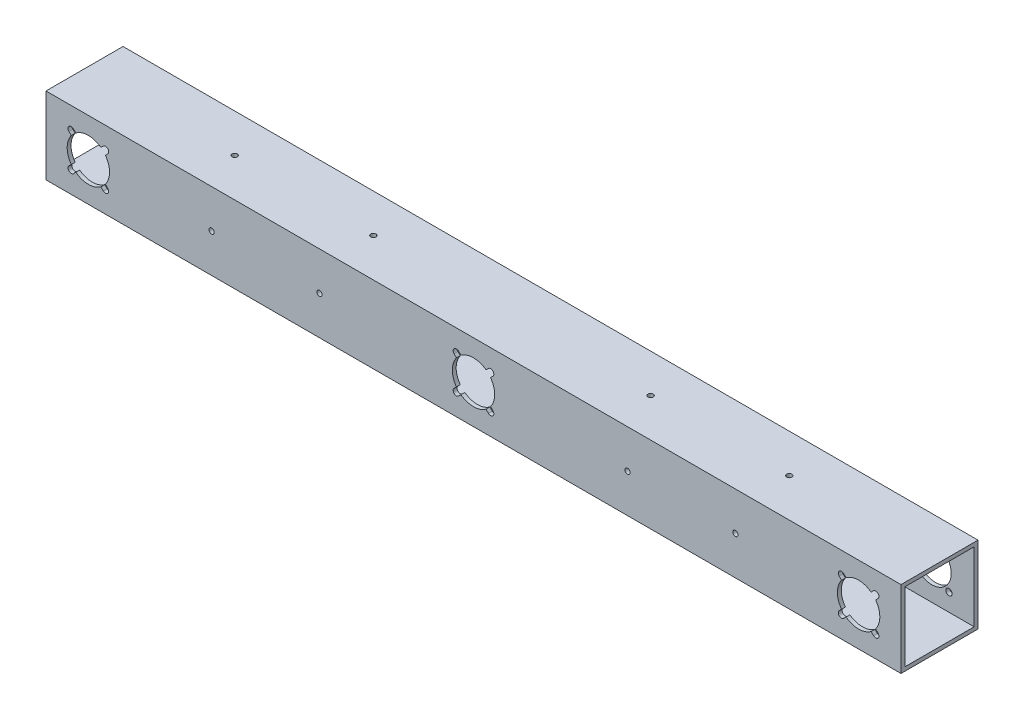
from build123d import *

# Parameters (mm, degrees)
SKETCH1_W           = 63.5
SKETCH1_H           = 63.5
BOSS_EXTRUDE1_DEPTH = 704.85
SKETCH2_W           = 57.15
SKETCH2_H           = 57.15
CUT_EXTRUDE1_DEPTH  = 705.85
CUT_EXTRUDE2_REACH  = 65.5
SKETCH3_R           = 17.4625
SKETCH8_R           = 2.15265
CUT_EXTRUDE6_DEPTH  = 64.5
SKETCH10_R          = 2.15265
CUT_EXTRUDE7_DEPTH  = 64.5
CUT_EXTRUDE9_REACH  = 65.5
SKETCH13_R          = 16
SKETCH14_R          = 2.625
SKETCH14_R_2        = 16
CUT_EXTRUDE10_DEPTH = 3.175
CUT_EXTRUDE11_START = -3.175
CUT_EXTRUDE11_DEPTH = 3.175
CUT_EXTRUDE13_REACH = 65.5
SKETCH17_W          = 19.05
SKETCH17_H          = 25.4


with BuildPart() as part:
    # Sketch1 → Boss-Extrude1 (new body)
    with BuildSketch(Plane(origin=(0, 0, 0), x_dir=(0, 0, -1), z_dir=(1, 0, 0))):
        Rectangle(SKETCH1_W, SKETCH1_H)
    extrude(amount=BOSS_EXTRUDE1_DEPTH)

    # Sketch2 → Cut-Extrude1 (cut, through all)
    with BuildSketch(Plane(origin=(704.85, 0, 0), x_dir=(0, 0, -1), z_dir=(1, 0, 0))):
        Rectangle(SKETCH2_W, SKETCH2_H)
    extrude(amount=-CUT_EXTRUDE1_DEPTH, mode=Mode.SUBTRACT)

    # Sketch3 → Cut-Extrude2 (cut, up to next)
    with BuildSketch(Plane.XY.offset(31.75), mode=Mode.PRIVATE) as cut_extrude2_sk1:
        with Locations((352.425, 0)):
            Circle(SKETCH3_R)
    cut_extrude2_tool1 = extrude(cut_extrude2_sk1.sketch, amount=-CUT_EXTRUDE2_REACH, mode=Mode.PRIVATE) & part.part
    add(cut_extrude2_tool1.solids().sort_by_distance((352.425, 0, 31.75))[0], mode=Mode.SUBTRACT)
    # Sketch3 → Cut-Extrude2 (cut, up to next)
    with BuildSketch(Plane.XY.offset(31.75), mode=Mode.PRIVATE) as cut_extrude2_sk2:
        with Locations((34.925, 0)):
            Circle(SKETCH3_R)
    cut_extrude2_tool2 = extrude(cut_extrude2_sk2.sketch, amount=-CUT_EXTRUDE2_REACH, mode=Mode.PRIVATE) & part.part
    add(cut_extrude2_tool2.solids().sort_by_distance((34.925, 0, 31.75))[0], mode=Mode.SUBTRACT)
    # Sketch3 → Cut-Extrude2 (cut, up to next)
    with BuildSketch(Plane.XY.offset(31.75), mode=Mode.PRIVATE) as cut_extrude2_sk3:
        with Locations((669.925, 0)):
            Circle(SKETCH3_R)
    cut_extrude2_tool3 = extrude(cut_extrude2_sk3.sketch, amount=-CUT_EXTRUDE2_REACH, mode=Mode.PRIVATE) & part.part
    add(cut_extrude2_tool3.solids().sort_by_distance((669.925, 0, 31.75))[0], mode=Mode.SUBTRACT)

    # Sketch8 → Cut-Extrude6 (cut, through all)
    with BuildSketch(Plane(origin=(0, 31.75, 0), x_dir=(1, 0, 0), z_dir=(0, 1, 0))):
        with Locations((466.725, 0)):
            Circle(SKETCH8_R)
        with Locations((123.825, 0)):
            Circle(SKETCH8_R)
        with Locations((581.025, 0)):
            Circle(SKETCH8_R)
        with Locations((238.125, 0)):
            Circle(SKETCH8_R)
    extrude(amount=-CUT_EXTRUDE6_DEPTH, mode=Mode.SUBTRACT)

    # Sketch10 → Cut-Extrude7 (cut, through all)
    with BuildSketch(Plane.XY.offset(31.75)):
        with Locations((225.425, 0)):
            Circle(SKETCH10_R)
        with Locations((568.325, 0)):
            Circle(SKETCH10_R)
        with Locations((136.525, 0)):
            Circle(SKETCH10_R)
        with Locations((479.425, 0)):
            Circle(SKETCH10_R)
    extrude(amount=-CUT_EXTRUDE7_DEPTH, mode=Mode.SUBTRACT)

    # Sketch13 → Cut-Extrude9 (cut, up to next)
    with BuildSketch(Plane(origin=(0, 0, -31.75), x_dir=(-1, 0, 0), z_dir=(0, 0, -1)), mode=Mode.PRIVATE) as cut_extrude9_sk1:
        with Locations((-352.425, 0)):
            Circle(SKETCH13_R)
    cut_extrude9_tool1 = extrude(cut_extrude9_sk1.sketch, amount=-CUT_EXTRUDE9_REACH, mode=Mode.PRIVATE) & part.part
    add(cut_extrude9_tool1.solids().sort_by_distance((352.425, 0, -31.75))[0], mode=Mode.SUBTRACT)
    # Sketch13 → Cut-Extrude9 (cut, up to next)
    with BuildSketch(Plane(origin=(0, 0, -31.75), x_dir=(-1, 0, 0), z_dir=(0, 0, -1)), mode=Mode.PRIVATE) as cut_extrude9_sk2:
        with Locations((-34.925, 0)):
            Circle(SKETCH13_R)
    cut_extrude9_tool2 = extrude(cut_extrude9_sk2.sketch, amount=-CUT_EXTRUDE9_REACH, mode=Mode.PRIVATE) & part.part
    add(cut_extrude9_tool2.solids().sort_by_distance((34.925, 0, -31.75))[0], mode=Mode.SUBTRACT)
    # Sketch13 → Cut-Extrude9 (cut, up to next)
    with BuildSketch(Plane(origin=(0, 0, -31.75), x_dir=(-1, 0, 0), z_dir=(0, 0, -1)), mode=Mode.PRIVATE) as cut_extrude9_sk3:
        with Locations((-669.925, 0)):
            Circle(SKETCH13_R)
    cut_extrude9_tool3 = extrude(cut_extrude9_sk3.sketch, amount=-CUT_EXTRUDE9_REACH, mode=Mode.PRIVATE) & part.part
    add(cut_extrude9_tool3.solids().sort_by_distance((669.925, 0, -31.75))[0], mode=Mode.SUBTRACT)

    # Sketch14 → Cut-Extrude10 (cut)
    with BuildSketch(Plane(origin=(0, 0, -31.75), x_dir=(-1, 0, 0), z_dir=(0, 0, -1))):
        with Locations((-655.782864376, 14.142135624)):
            Circle(SKETCH14_R)
        with Locations((-338.282864376, 14.142135624)):
            Circle(SKETCH14_R)
        with Locations((-20.782864376, 14.142135624)):
            Circle(SKETCH14_R)
        with Locations((-352.425, 0)):
            Circle(SKETCH14_R_2)
        with Locations((-34.925, 0)):
            Circle(SKETCH14_R_2)
        with Locations((-669.925, 0)):
            Circle(SKETCH14_R_2)
        with Locations((-338.282864376, -14.142135624)):
            Circle(SKETCH14_R)
        with Locations((-366.567135624, -14.142135624)):
            Circle(SKETCH14_R)
        with Locations((-366.567135624, 14.142135624)):
            Circle(SKETCH14_R)
        with Locations((-20.782864376, -14.142135624)):
            Circle(SKETCH14_R)
        with Locations((-49.067135624, -14.142135624)):
            Circle(SKETCH14_R)
        with Locations((-49.067135624, 14.142135624)):
            Circle(SKETCH14_R)
        with Locations((-655.782864376, -14.142135624)):
            Circle(SKETCH14_R)
        with Locations((-684.067135624, -14.142135624)):
            Circle(SKETCH14_R)
        with Locations((-684.067135624, 14.142135624)):
            Circle(SKETCH14_R)
    extrude(amount=-CUT_EXTRUDE10_DEPTH, mode=Mode.SUBTRACT)

    # Sketch15 → Cut-Extrude11 (cut)
    with BuildSketch(Plane.XY.offset(31.75).offset(CUT_EXTRUDE11_START)):
        with BuildLine():
            Line((364.710980323, -15.998290924), (362.776389114, -14.063699715))
            ThreePointArc((362.776389114, -14.063699715), (352.425, -17.4625), (342.073610886, -14.063699715))
            Line((342.073610886, -14.063699715), (340.139019677, -15.998290924))
            ThreePointArc((340.139019677, -15.998290924), (336.426709076, -15.998290924), (336.426709076, -12.285980323))
            Line((336.426709076, -12.285980323), (338.361300285, -10.351389114))
            ThreePointArc((338.361300285, -10.351389114), (334.9625, 0), (338.361300285, 10.351389114))
            Line((338.361300285, 10.351389114), (336.426709076, 12.285980323))
            ThreePointArc((336.426709076, 12.285980323), (336.426709076, 15.998290924), (340.139019677, 15.998290924))
            Line((340.139019677, 15.998290924), (342.073610886, 14.063699715))
            ThreePointArc((342.073610886, 14.063699715), (352.425, 17.4625), (362.776389114, 14.063699715))
            Line((362.776389114, 14.063699715), (364.710980323, 15.998290924))
            ThreePointArc((364.710980323, 15.998290924), (368.423290924, 15.998290924), (368.423290924, 12.285980323))
            Line((368.423290924, 12.285980323), (366.488699715, 10.351389114))
            ThreePointArc((366.488699715, 10.351389114), (369.8875, 0), (366.488699715, -10.351389114))
            Line((366.488699715, -10.351389114), (368.423290924, -12.285980323))
            ThreePointArc((368.423290924, -12.285980323), (368.423290924, -15.998290924), (364.710980323, -15.998290924))
        make_face()
        with BuildLine():
            Line((50.923290924, 12.285980323), (48.988699715, 10.351389114))
            ThreePointArc((48.988699715, 10.351389114), (52.3875, 0), (48.988699715, -10.351389114))
            Line((48.988699715, -10.351389114), (50.923290924, -12.285980323))
            ThreePointArc((50.923290924, -12.285980323), (50.923290924, -15.998290924), (47.210980323, -15.998290924))
            Line((47.210980323, -15.998290924), (45.276389114, -14.063699715))
            ThreePointArc((45.276389114, -14.063699715), (34.925, -17.4625), (24.573610886, -14.063699715))
            Line((24.573610886, -14.063699715), (22.639019677, -15.998290924))
            ThreePointArc((22.639019677, -15.998290924), (18.926709076, -15.998290924), (18.926709076, -12.285980323))
            Line((18.926709076, -12.285980323), (20.861300285, -10.351389114))
            ThreePointArc((20.861300285, -10.351389114), (17.4625, 0), (20.861300285, 10.351389114))
            Line((20.861300285, 10.351389114), (18.926709076, 12.285980323))
            ThreePointArc((18.926709076, 12.285980323), (18.926709076, 15.998290924), (22.639019677, 15.998290924))
            Line((22.639019677, 15.998290924), (24.573610886, 14.063699715))
            ThreePointArc((24.573610886, 14.063699715), (34.925, 17.4625), (45.276389114, 14.063699715))
            Line((45.276389114, 14.063699715), (47.210980323, 15.998290924))
            ThreePointArc((47.210980323, 15.998290924), (50.923290924, 15.998290924), (50.923290924, 12.285980323))
        make_face()
        with BuildLine():
            Line((685.923290924, 12.285980323), (683.988699715, 10.351389114))
            ThreePointArc((683.988699715, 10.351389114), (687.3875, 0), (683.988699715, -10.351389114))
            Line((683.988699715, -10.351389114), (685.923290924, -12.285980323))
            ThreePointArc((685.923290924, -12.285980323), (685.923290924, -15.998290924), (682.210980323, -15.998290924))
            Line((682.210980323, -15.998290924), (680.276389114, -14.063699715))
            ThreePointArc((680.276389114, -14.063699715), (669.925, -17.4625), (659.573610886, -14.063699715))
            Line((659.573610886, -14.063699715), (657.639019677, -15.998290924))
            ThreePointArc((657.639019677, -15.998290924), (653.926709076, -15.998290924), (653.926709076, -12.285980323))
            Line((653.926709076, -12.285980323), (655.861300285, -10.351389114))
            ThreePointArc((655.861300285, -10.351389114), (652.4625, 0), (655.861300285, 10.351389114))
            Line((655.861300285, 10.351389114), (653.926709076, 12.285980323))
            ThreePointArc((653.926709076, 12.285980323), (653.926709076, 15.998290924), (657.639019677, 15.998290924))
            Line((657.639019677, 15.998290924), (659.573610886, 14.063699715))
            ThreePointArc((659.573610886, 14.063699715), (669.925, 17.4625), (680.276389114, 14.063699715))
            Line((680.276389114, 14.063699715), (682.210980323, 15.998290924))
            ThreePointArc((682.210980323, 15.998290924), (685.923290924, 15.998290924), (685.923290924, 12.285980323))
        make_face()
    extrude(amount=CUT_EXTRUDE11_DEPTH, mode=Mode.SUBTRACT)

    # Sketch17 → Cut-Extrude13 (cut, up to next)
    with BuildSketch(Plane.XZ.offset(31.75), mode=Mode.PRIVATE) as cut_extrude13_sk1:
        with Locations((352.425, -12.7)):
            Rectangle(SKETCH17_W, SKETCH17_H)
    cut_extrude13_tool1 = extrude(cut_extrude13_sk1.sketch, amount=-CUT_EXTRUDE13_REACH, mode=Mode.PRIVATE) & part.part
    add(cut_extrude13_tool1.solids().sort_by_distance((352.425, -31.75, -12.7))[0], mode=Mode.SUBTRACT)


solid = part.part
